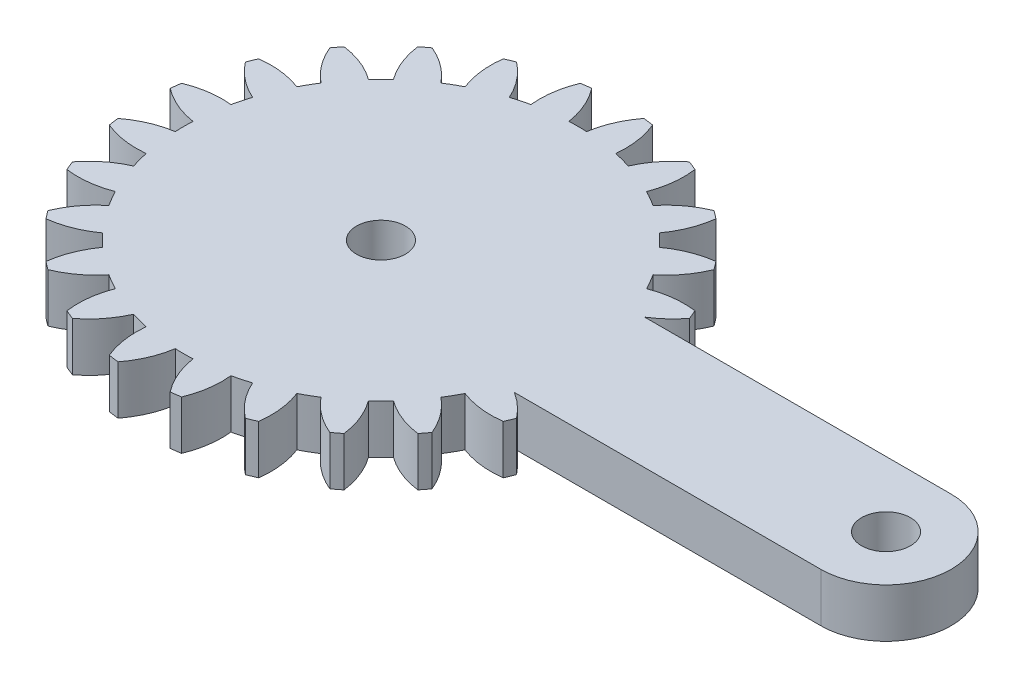
from build123d import *

# Parameters (mm, degrees)
SKETCH1_R           = 1.5
BOSS_EXTRUDE1_DEPTH = 1.5


with BuildPart() as part:
    # Sketch1 → Boss-Extrude1 (new body, symmetric)
    with BuildSketch(Plane(origin=(0, 0, 0), x_dir=(1, 0, 0), z_dir=(0, 1, 0))):
        with BuildLine():
            Line((11.067960149, -3.770386358), (29.879975659, -3.770386358))
            ThreePointArc((29.879975659, -3.770386358), (33.879975659, 0.229613642), (29.879975659, 4.229613642))
            Line((29.879975659, 4.229613642), (11.067960149, 4.229613642))
            ThreePointArc((11.067960149, 4.229613642), (11.847346546, 4.817815376), (12.508067649, 5.536753523))
            ThreePointArc((12.508067649, 5.536753523), (12.391713822, 5.826358841), (12.269206518, 6.113415305))
            ThreePointArc((12.269206518, 6.113415305), (10.921594192, 6.123653667), (9.613413173, 5.799884882))
            ThreePointArc((9.613413173, 5.799884882), (9.35260436, 6.275988642), (9.070690816, 6.73990758))
            ThreePointArc((9.070690816, 6.73990758), (10.005173318, 7.710941183), (10.670112799, 8.883126872))
            ThreePointArc((10.670112799, 8.883126872), (10.482768261, 9.132749542), (10.290139612, 9.378317571))
            ThreePointArc((10.290139612, 9.378317571), (8.985796179, 9.039419334), (7.805987876, 8.38810054))
            ThreePointArc((7.805987876, 8.38810054), (7.430841187, 8.780479171), (7.038462557, 9.155625859))
            ThreePointArc((7.038462557, 9.155625859), (7.68978135, 10.335434163), (8.028679587, 11.639777595))
            ThreePointArc((8.028679587, 11.639777595), (7.783111558, 11.832406244), (7.533488888, 12.019750783))
            ThreePointArc((7.533488888, 12.019750783), (6.361303199, 11.354811301), (5.390269597, 10.420328799))
            ThreePointArc((5.390269597, 10.420328799), (4.926350659, 10.702242344), (4.450246898, 10.963051157))
            ThreePointArc((4.450246898, 10.963051157), (4.774015684, 12.271232176), (4.763777322, 13.618844501))
            ThreePointArc((4.763777322, 13.618844501), (4.476720857, 13.741351805), (4.187115539, 13.857705633))
            ThreePointArc((4.187115539, 13.857705633), (3.22697011, 12.912039434), (2.530885544, 11.758076661))
            ThreePointArc((2.530885544, 11.758076661), (2.009809666, 11.910313178), (1.48242646, 12.039010426))
            ThreePointArc((1.48242646, 12.039010426), (1.45658093, 13.386413785), (1.097903696, 14.685457451))
            ThreePointArc((1.097903696, 14.685457451), (0.78892122, 14.72949474), (0.479069377, 14.766928535))
            ThreePointArc((0.479069377, 14.766928535), (-0.203603467, 13.604981207), (-0.577301983, 12.31017882))
            ThreePointArc((-0.577301983, 12.31017882), (-1.120024341, 12.322363642), (-1.662746699, 12.31017882))
            ThreePointArc((-1.662746699, 12.31017882), (-2.036445216, 13.604981207), (-2.71911806, 14.766928535))
            ThreePointArc((-2.71911806, 14.766928535), (-3.028969902, 14.72949474), (-3.337952378, 14.685457451))
            ThreePointArc((-3.337952378, 14.685457451), (-3.696629612, 13.386413785), (-3.722475143, 12.039010426))
            ThreePointArc((-3.722475143, 12.039010426), (-4.249858349, 11.910313178), (-4.770934227, 11.758076661))
            ThreePointArc((-4.770934227, 11.758076661), (-5.467018792, 12.912039434), (-6.427164221, 13.857705633))
            ThreePointArc((-6.427164221, 13.857705633), (-6.71676954, 13.741351805), (-7.003826004, 13.618844501))
            ThreePointArc((-7.003826004, 13.618844501), (-7.014064366, 12.271232176), (-6.690295581, 10.963051157))
            ThreePointArc((-6.690295581, 10.963051157), (-7.166399341, 10.702242344), (-7.630318279, 10.420328799))
            ThreePointArc((-7.630318279, 10.420328799), (-8.601351881, 11.354811301), (-9.773537571, 12.019750783))
            ThreePointArc((-9.773537571, 12.019750783), (-10.02316024, 11.832406244), (-10.26872827, 11.639777595))
            ThreePointArc((-10.26872827, 11.639777595), (-9.929830033, 10.335434163), (-9.278511239, 9.155625859))
            ThreePointArc((-9.278511239, 9.155625859), (-9.670889869, 8.780479171), (-10.046036558, 8.38810054))
            ThreePointArc((-10.046036558, 8.38810054), (-11.225844862, 9.039419334), (-12.530188294, 9.378317571))
            ThreePointArc((-12.530188294, 9.378317571), (-12.722816943, 9.132749542), (-12.910161481, 8.883126872))
            ThreePointArc((-12.910161481, 8.883126872), (-12.245222, 7.710941183), (-11.310739498, 6.73990758))
            ThreePointArc((-11.310739498, 6.73990758), (-11.592653043, 6.275988642), (-11.853461856, 5.799884882))
            ThreePointArc((-11.853461856, 5.799884882), (-13.161642874, 6.123653667), (-14.5092552, 6.113415305))
            ThreePointArc((-14.5092552, 6.113415305), (-14.631762504, 5.826358841), (-14.748116331, 5.536753523))
            ThreePointArc((-14.748116331, 5.536753523), (-13.802450133, 4.576608094), (-12.64848736, 3.880523528))
            ThreePointArc((-12.64848736, 3.880523528), (-12.800723877, 3.35944765), (-12.929421125, 2.832064444))
            ThreePointArc((-12.929421125, 2.832064444), (-14.276824484, 2.806218913), (-15.57586815, 2.44754168))
            ThreePointArc((-15.57586815, 2.44754168), (-15.619905439, 2.138559204), (-15.657339233, 1.828707361))
            ThreePointArc((-15.657339233, 1.828707361), (-14.495391906, 1.146034517), (-13.200589518, 0.772336))
            ThreePointArc((-13.200589518, 0.772336), (-13.212774341, 0.229613642), (-13.200589518, -0.313108715))
            ThreePointArc((-13.200589518, -0.313108715), (-14.495391906, -0.686807232), (-15.657339233, -1.369480076))
            ThreePointArc((-15.657339233, -1.369480076), (-15.619905439, -1.679331919), (-15.57586815, -1.988314395))
            ThreePointArc((-15.57586815, -1.988314395), (-14.276824484, -2.346991628), (-12.929421125, -2.372837159))
            ThreePointArc((-12.929421125, -2.372837159), (-12.800723877, -2.900220365), (-12.64848736, -3.421296243))
            ThreePointArc((-12.64848736, -3.421296243), (-13.802450133, -4.117380809), (-14.748116331, -5.077526238))
            ThreePointArc((-14.748116331, -5.077526238), (-14.631762504, -5.367131556), (-14.5092552, -5.65418802))
            ThreePointArc((-14.5092552, -5.65418802), (-13.161642874, -5.664426382), (-11.853461856, -5.340657597))
            ThreePointArc((-11.853461856, -5.340657597), (-11.592653043, -5.816761358), (-11.310739498, -6.280680295))
            ThreePointArc((-11.310739498, -6.280680295), (-12.245222, -7.251713898), (-12.910161481, -8.423899587))
            ThreePointArc((-12.910161481, -8.423899587), (-12.722816943, -8.673522257), (-12.530188294, -8.919090286))
            ThreePointArc((-12.530188294, -8.919090286), (-11.225844862, -8.580192049), (-10.046036558, -7.928873256))
            ThreePointArc((-10.046036558, -7.928873256), (-9.670889869, -8.321251886), (-9.278511239, -8.696398575))
            ThreePointArc((-9.278511239, -8.696398575), (-9.929830033, -9.876206878), (-10.26872827, -11.18055031))
            ThreePointArc((-10.26872827, -11.18055031), (-10.02316024, -11.373178959), (-9.773537571, -11.560523498))
            ThreePointArc((-9.773537571, -11.560523498), (-8.601351881, -10.895584017), (-7.630318279, -9.961101514))
            ThreePointArc((-7.630318279, -9.961101514), (-7.166399341, -10.243015059), (-6.690295581, -10.503823872))
            ThreePointArc((-6.690295581, -10.503823872), (-7.014064366, -11.812004891), (-7.003826004, -13.159617217))
            ThreePointArc((-7.003826004, -13.159617217), (-6.71676954, -13.282124521), (-6.427164222, -13.398478348))
            ThreePointArc((-6.427164222, -13.398478348), (-5.467018793, -12.452812149), (-4.770934227, -11.298849376))
            ThreePointArc((-4.770934227, -11.298849376), (-4.249858349, -11.451085894), (-3.722475143, -11.579783141))
            ThreePointArc((-3.722475143, -11.579783141), (-3.696629612, -12.9271865), (-3.337952379, -14.226230166))
            ThreePointArc((-3.337952379, -14.226230166), (-3.028969902, -14.270267455), (-2.71911806, -14.30770125))
            ThreePointArc((-2.71911806, -14.30770125), (-2.036445216, -13.145753923), (-1.662746699, -11.850951535))
            ThreePointArc((-1.662746699, -11.850951535), (-1.120024341, -11.863136358), (-0.577301983, -11.850951535))
            ThreePointArc((-0.577301983, -11.850951535), (-0.203603467, -13.145753923), (0.479069377, -14.30770125))
            ThreePointArc((0.479069377, -14.30770125), (0.78892122, -14.270267455), (1.097903696, -14.226230166))
            ThreePointArc((1.097903696, -14.226230166), (1.45658093, -12.9271865), (1.48242646, -11.579783141))
            ThreePointArc((1.48242646, -11.579783141), (2.009809666, -11.451085893), (2.530885544, -11.298849376))
            ThreePointArc((2.530885544, -11.298849376), (3.22697011, -12.452812149), (4.187115539, -13.398478348))
            ThreePointArc((4.187115539, -13.398478348), (4.476720857, -13.282124521), (4.763777322, -13.159617216))
            ThreePointArc((4.763777322, -13.159617216), (4.774015684, -11.812004891), (4.450246898, -10.503823872))
            ThreePointArc((4.450246898, -10.503823872), (4.926350659, -10.243015059), (5.390269597, -9.961101514))
            ThreePointArc((5.390269597, -9.961101514), (6.361303199, -10.895584017), (7.533488888, -11.560523498))
            ThreePointArc((7.533488888, -11.560523498), (7.783111558, -11.373178959), (8.028679587, -11.18055031))
            ThreePointArc((8.028679587, -11.18055031), (7.68978135, -9.876206878), (7.038462557, -8.696398575))
            ThreePointArc((7.038462557, -8.696398575), (7.430841187, -8.321251886), (7.805987876, -7.928873256))
            ThreePointArc((7.805987876, -7.928873256), (8.985796179, -8.580192049), (10.290139612, -8.919090286))
            ThreePointArc((10.290139612, -8.919090286), (10.482768261, -8.673522257), (10.670112799, -8.423899587))
            ThreePointArc((10.670112799, -8.423899587), (10.005173318, -7.251713898), (9.070690816, -6.280680295))
            ThreePointArc((9.070690816, -6.280680295), (9.35260436, -5.816761358), (9.613413173, -5.340657597))
            ThreePointArc((9.613413173, -5.340657597), (10.921594192, -5.664426382), (12.269206518, -5.65418802))
            ThreePointArc((12.269206518, -5.65418802), (12.391713822, -5.367131556), (12.508067649, -5.077526238))
            ThreePointArc((12.508067649, -5.077526238), (11.847346546, -4.358588091), (11.067960149, -3.770386358))
        make_face()
        with Locations((29.879975659, 0.229613642)):
            Circle(SKETCH1_R, mode=Mode.SUBTRACT)
        with Locations((-1.120024341, 0.229613642)):
            Circle(SKETCH1_R, mode=Mode.SUBTRACT)
    extrude(amount=BOSS_EXTRUDE1_DEPTH, both=True)


solid = part.part
